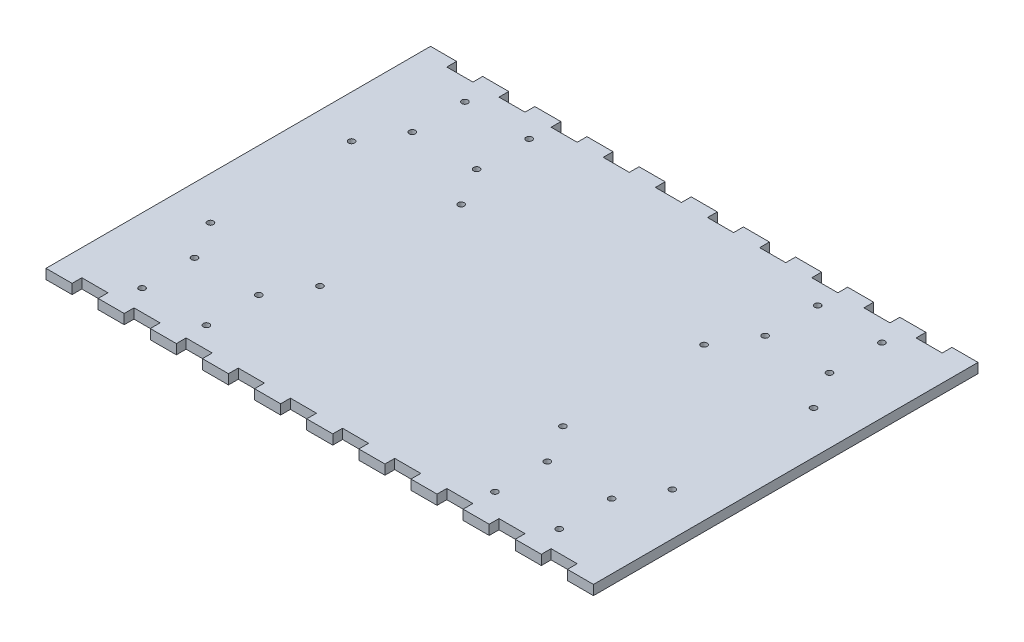
from build123d import *

# Parameters (mm, degrees)
BOSS_EXTRUDE1_DEPTH = 4.7625
SKETCH5_R           = 1.5
CUT_EXTRUDE1_DEPTH  = 5.7625


with BuildPart() as part:
    # Sketch2 → Boss-Extrude1 (new body)
    with BuildSketch(Plane(origin=(0, 0, 0), x_dir=(1, 0, 0), z_dir=(0, 1, 0))):
        Polygon((25.4, 88.9), (25.4, 93.6625), (38.1, 93.6625), (38.1, 88.9), (50.8, 88.9), (50.8, 93.6625), (63.5, 93.6625), (63.5, 88.9), (76.2, 88.9), (76.2, 93.6625), (88.9, 93.6625), (88.9, 88.9), (101.6, 88.9), (101.6, 93.6625), (114.3, 93.6625), (114.3, 88.9), (127, 88.9), (127, 93.6625), (139.7, 93.6625), (139.7, 88.9), (152.4, 88.9), (152.4, 93.6625), (165.1, 93.6625), (165.1, 88.9), (177.8, 88.9), (177.8, 93.6625), (190.5, 93.6625), (190.5, 88.9), (203.2, 88.9), (203.2, 93.6625), (215.9, 93.6625), (215.9, 88.9), (228.6, 88.9), (228.6, 93.6625), (241.3, 93.6625), (241.3, 88.9), (254, 88.9), (254, 93.6625), (266.7, 93.6625), (266.7, 88.9), (266.7, -88.9), (266.7, -93.6625), (254, -93.6625), (254, -88.9), (241.3, -88.9), (241.3, -93.6625), (228.6, -93.6625), (228.6, -88.9), (215.9, -88.9), (215.9, -93.6625), (203.2, -93.6625), (203.2, -88.9), (190.5, -88.9), (190.5, -93.6625), (177.8, -93.6625), (177.8, -88.9), (165.1, -88.9), (165.1, -93.6625), (152.4, -93.6625), (152.4, -88.9), (139.7, -88.9), (139.7, -93.6625), (127, -93.6625), (127, -88.9), (114.3, -88.9), (114.3, -93.6625), (101.6, -93.6625), (101.6, -88.9), (88.9, -88.9), (88.9, -93.6625), (76.2, -93.6625), (76.2, -88.9), (63.5, -88.9), (63.5, -93.6625), (50.8, -93.6625), (50.8, -88.9), (38.1, -88.9), (38.1, -93.6625), (25.4, -93.6625), (25.4, -88.9), (12.7, -88.9), (12.7, -93.6625), (0, -93.6625), (0, -88.9), (0, 88.9), (0, 93.6625), (12.7, 93.6625), (12.7, 88.9), align=None)
    extrude(amount=BOSS_EXTRUDE1_DEPTH)

    # Sketch5 → Cut-Extrude1 (cut, through all)
    with BuildSketch(Plane(origin=(0, 4.7625, 0), x_dir=(1, 0, 0), z_dir=(0, 1, 0))):
        with Locations((31.75, 78.6125)):
            Circle(SKETCH5_R)
        with Locations((63.07, 78.6125)):
            Circle(SKETCH5_R)
        with Locations((63.07, 53.0625)):
            Circle(SKETCH5_R)
        with Locations((31.75, 53.0625)):
            Circle(SKETCH5_R)
        with Locations((203.63, 78.6125)):
            Circle(SKETCH5_R)
        with Locations((203.63, 53.0625)):
            Circle(SKETCH5_R)
        with Locations((234.95, 53.0625)):
            Circle(SKETCH5_R)
        with Locations((234.95, 78.6125)):
            Circle(SKETCH5_R)
        with Locations((234.95, -78.6125)):
            Circle(SKETCH5_R)
        with Locations((234.95, -53.0625)):
            Circle(SKETCH5_R)
        with Locations((203.63, -53.0625)):
            Circle(SKETCH5_R)
        with Locations((203.63, -78.6125)):
            Circle(SKETCH5_R)
        with Locations((31.75, -53.0625)):
            Circle(SKETCH5_R)
        with Locations((63.07, -53.0625)):
            Circle(SKETCH5_R)
        with Locations((63.07, -78.6125)):
            Circle(SKETCH5_R)
        with Locations((31.75, -78.6125)):
            Circle(SKETCH5_R)
        with Locations((20.83, 34.385)):
            Circle(SKETCH5_R)
        with Locations((74.17, 34.385)):
            Circle(SKETCH5_R)
        with Locations((192.53, 34.385)):
            Circle(SKETCH5_R)
        with Locations((245.87, 34.385)):
            Circle(SKETCH5_R)
        with Locations((245.87, -34.385)):
            Circle(SKETCH5_R)
        with Locations((192.53, -34.385)):
            Circle(SKETCH5_R)
        with Locations((74.17, -34.385)):
            Circle(SKETCH5_R)
        with Locations((20.83, -34.385)):
            Circle(SKETCH5_R)
    extrude(amount=-CUT_EXTRUDE1_DEPTH, mode=Mode.SUBTRACT)


solid = part.part
